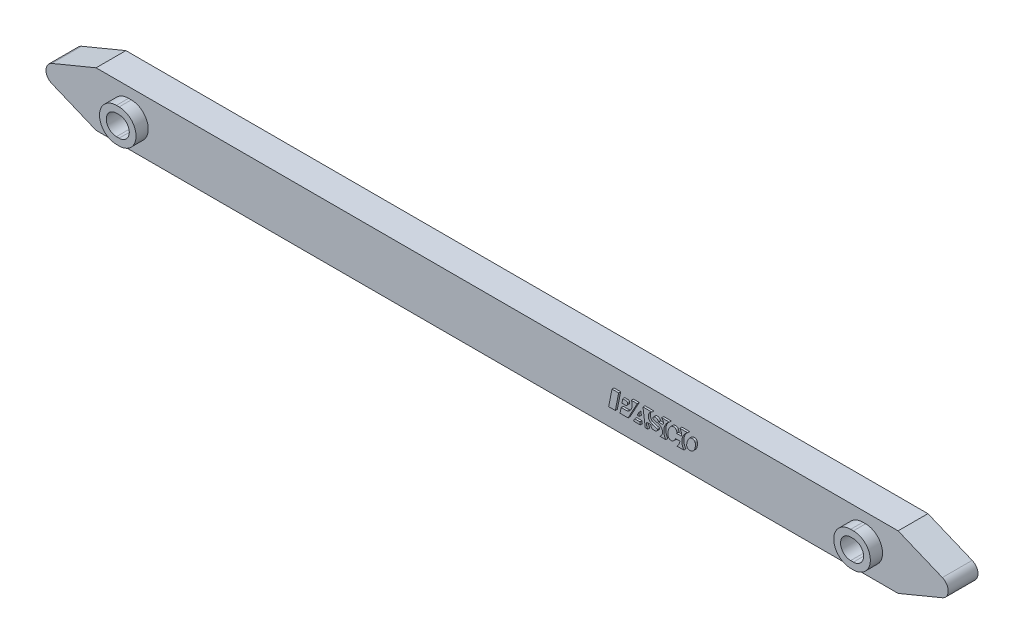
from build123d import *

# Parameters (mm, degrees)
EXTRUDE1_DEPTH      = 2.794
CUT_EXTRUDE1_DEPTH  = 6.588
SHELL2_T            = 1.016
BOSS_EXTRUDE1_DEPTH = 5.08
BOSS_EXTRUDE2_DEPTH = 0.381


with BuildPart() as part:
    # Sketch1 → Extrude1 (new body, symmetric)
    with BuildSketch(Plane.XY):
        with BuildLine():
            Line((-83.497972353, 1.642657809), (-75.199494217, 5.08))
            Line((-75.199494217, 5.08), (75.199494217, 5.08))
            Line((75.199494217, 5.08), (83.497972353, 1.642657809))
            ThreePointArc((83.497972353, 1.642657809), (84.595561211, 0), (83.497972353, -1.642657809))
            Line((83.497972353, -1.642657809), (75.199494217, -5.08))
            Line((75.199494217, -5.08), (-75.199494217, -5.08))
            Line((-75.199494217, -5.08), (-83.497972353, -1.642657809))
            ThreePointArc((-83.497972353, -1.642657809), (-84.595561211, 0), (-83.497972353, 1.642657809))
        make_face()
    extrude(amount=EXTRUDE1_DEPTH, both=True)

    # Sketch7 → Cut-Extrude1 (cut, through all)
    with BuildSketch(Plane.XY.offset(-2.794)):
        with BuildLine():
            Line((-69.101561211, -1.905), (-68.593561211, -1.905))
            ThreePointArc((-68.593561211, -1.905), (-66.688561211, 0), (-68.593561211, 1.905))
            Line((-68.593561211, 1.905), (-69.101561211, 1.905))
            ThreePointArc((-69.101561211, 1.905), (-71.006561211, 0), (-69.101561211, -1.905))
        make_face()
        with BuildLine():
            Line((69.101561211, -1.905), (68.593561211, -1.905))
            ThreePointArc((68.593561211, -1.905), (66.688561211, 0), (68.593561211, 1.905))
            Line((68.593561211, 1.905), (69.101561211, 1.905))
            ThreePointArc((69.101561211, 1.905), (71.006561211, 0), (69.101561211, -1.905))
        make_face()
    extrude(amount=CUT_EXTRUDE1_DEPTH, mode=Mode.SUBTRACT)

    # Shell2 (no face opened: a closed hollow body)
    add(offset(amount=-SHELL2_T, mode=Mode.PRIVATE), mode=Mode.SUBTRACT)

    # Sketch16 → Boss-Extrude1 (add)
    with BuildSketch(Plane.XY):
        with BuildLine():
            Line((-68.593561211, 3.175), (-69.101561211, 3.175))
            ThreePointArc((-69.101561211, 3.175), (-72.276561211, 0), (-69.101561211, -3.175))
            Line((-69.101561211, -3.175), (-68.593561211, -3.175))
            ThreePointArc((-68.593561211, -3.175), (-65.418561211, 0), (-68.593561211, 3.175))
        make_face()
        with BuildLine():
            Line((-68.593561211, 1.905), (-69.101561211, 1.905))
            ThreePointArc((-69.101561211, 1.905), (-71.006561211, 0), (-69.101561211, -1.905))
            Line((-69.101561211, -1.905), (-68.593561211, -1.905))
            ThreePointArc((-68.593561211, -1.905), (-66.688561211, 0), (-68.593561211, 1.905))
        make_face(mode=Mode.SUBTRACT)
        with BuildLine():
            Line((69.101561211, -3.175), (68.593561211, -3.175))
            ThreePointArc((68.593561211, -3.175), (65.418561211, 0), (68.593561211, 3.175))
            Line((68.593561211, 3.175), (69.101561211, 3.175))
            ThreePointArc((69.101561211, 3.175), (72.276561211, 0), (69.101561211, -3.175))
        make_face()
        with BuildLine():
            Line((69.101561211, -1.905), (68.593561211, -1.905))
            ThreePointArc((68.593561211, -1.905), (66.688561211, 0), (68.593561211, 1.905))
            Line((68.593561211, 1.905), (69.101561211, 1.905))
            ThreePointArc((69.101561211, 1.905), (71.006561211, 0), (69.101561211, -1.905))
        make_face(mode=Mode.SUBTRACT)
    extrude(amount=BOSS_EXTRUDE1_DEPTH)

    # Sketch15 → Boss-Extrude2 (add)
    with BuildSketch(Plane(origin=(52.759975214, 8.567310029, 2.794), x_dir=(-1, 0, 0), z_dir=(0, 0, 1))):
        Polygon((30.833634894, 6.909260745), (29.58586719, 6.909260745), (30.209751042, 10.080670326), (31.457518746, 10.080670326), align=None)
        with BuildLine():
            Line((26.098109724, 6.909260745), (27.818196276, 10.080670326))
            Line((27.818196276, 10.080670326), (29.325915585, 10.080670326))
            Line((29.325915585, 10.080670326), (29.121363503, 9.040863906))
            Line((29.121363503, 9.040863906), (28.076751324, 9.040863906))
            ThreePointArc((28.076751324, 9.040863906), (27.966243867, 9.027758301), (27.861867206, 8.989168567))
            ThreePointArc((27.861867206, 8.989168567), (27.110933968, 8.112530186), (27.194312424, 6.961251066))
            Line((27.194312424, 6.961251066), (27.220239704, 6.909260745))
            Line((27.220239704, 6.909260745), (26.098109724, 6.909260745))
        make_face()
        with BuildLine():
            Line((24.594796374, 10.080670326), (25.024818012, 6.909260745))
            Line((25.024818012, 6.909260745), (23.345351563, 6.909260745))
            Line((23.345351563, 6.909260745), (23.451009312, 6.961251066))
            ThreePointArc((23.451009312, 6.961251066), (24.013843502, 7.721578938), (23.720459983, 8.620915865))
            ThreePointArc((23.720459983, 8.620915865), (23.664057171, 8.668518488), (23.600928958, 8.706756109))
            ThreePointArc((23.600928958, 8.706756109), (23.03751713, 8.93797936), (22.445309842, 9.080062458))
            ThreePointArc((22.445309842, 9.080062458), (22.355999269, 9.127094259), (22.313587173, 9.218688925))
            ThreePointArc((22.313587173, 9.218688925), (22.320050836, 9.315750612), (22.359212571, 9.404796153))
            ThreePointArc((22.359212571, 9.404796153), (22.441078376, 9.50688825), (22.550436966, 9.578759697))
            ThreePointArc((22.550436966, 9.578759697), (22.912840286, 9.660745811), (23.278270345, 9.593524078))
            ThreePointArc((23.278270345, 9.593524078), (23.448349032, 9.45576593), (23.512332705, 9.246457171))
            Line((23.512332705, 9.246457171), (23.512332705, 9.040863906))
            Line((23.512332705, 9.040863906), (24.334844769, 9.040863906))
            ThreePointArc((24.334844769, 9.040863906), (24.341195101, 9.582833311), (24.126883485, 10.080670326))
            Line((24.126883485, 10.080670326), (24.594796374, 10.080670326))
        make_face()
        with BuildLine():
            Line((28.312104326, 8.261009091), (28.967949441, 8.261009091))
            Line((28.967949441, 8.261009091), (28.814535379, 7.481154276))
            Line((28.814535379, 7.481154276), (28.209554826, 7.481154276))
            ThreePointArc((28.209554826, 7.481154276), (28.006347959, 7.565325317), (27.922176918, 7.768532184))
            Line((27.922176918, 7.768532184), (27.922176918, 7.871081684))
            ThreePointArc((27.922176918, 7.871081684), (28.036384012, 8.146801998), (28.312104326, 8.261009091))
        make_face()
        Polygon((25.790573757, 8.16352724), (25.706860528, 8.780912301), (26.125426672, 8.780912301), align=None)
        Polygon((25.530622152, 10.080670326), (26.830380177, 10.080670326), (26.576596915, 9.612757437), (25.594067968, 9.612757437), align=None)
        with BuildLine():
            Line((21.446019985, 6.986900983), (21.527856602, 6.905064366))
            Line((21.527856602, 6.905064366), (20.072127614, 6.905064366))
            ThreePointArc((20.072127614, 6.905064366), (21.073440916, 8.351729074), (20.74751262, 10.080670326))
            Line((20.74751262, 10.080670326), (21.839309361, 10.080670326))
            ThreePointArc((21.839309361, 10.080670326), (21.359771514, 9.203641008), (21.828371735, 8.320719265))
            ThreePointArc((21.828371735, 8.320719265), (21.970498458, 8.242561464), (22.123897961, 8.189861942))
            Line((22.123897961, 8.189861942), (22.959965448, 7.98084507))
            ThreePointArc((22.959965448, 7.98084507), (23.09929103, 7.88260745), (23.136218517, 7.716178461))
            ThreePointArc((23.136218517, 7.716178461), (23.063353728, 7.552354455), (22.917107557, 7.44862577))
            ThreePointArc((22.917107557, 7.44862577), (22.408346515, 7.486786133), (22.100511774, 7.893642107))
            Line((22.100511774, 7.893642107), (21.268666638, 7.893642107))
            ThreePointArc((21.268666638, 7.893642107), (21.219023851, 7.413217054), (21.446019985, 6.986900983))
        make_face()
        with BuildLine():
            Line((18.096006249, 6.909260745), (16.640277261, 6.909260745))
            ThreePointArc((16.640277261, 6.909260745), (17.684029363, 8.338941307), (17.368141755, 10.080670326))
            Line((17.368141755, 10.080670326), (18.66789978, 10.080670326))
            ThreePointArc((18.66789978, 10.080670326), (18.288993246, 9.583465168), (18.096006249, 8.988873585))
            Line((18.096006249, 8.988873585), (18.927851385, 8.988873585))
            ThreePointArc((18.927851385, 8.988873585), (19.124730401, 9.376543005), (19.462251482, 9.650638693))
            ThreePointArc((19.462251482, 9.650638693), (20.018996521, 9.643076799), (20.333746509, 9.183778785))
            ThreePointArc((20.333746509, 9.183778785), (20.297634521, 8.424922889), (20.010357156, 7.72161779))
            ThreePointArc((20.010357156, 7.72161779), (19.734264238, 7.404457918), (19.340648899, 7.256523307))
            ThreePointArc((19.340648899, 7.256523307), (18.807293319, 7.48101259), (18.719890101, 8.053047807))
            Line((18.719890101, 8.053047807), (17.784064323, 8.053047807))
            ThreePointArc((17.784064323, 8.053047807), (17.822649734, 7.449140035), (18.096006249, 6.909260745))
        make_face()
        with BuildLine():
            Line((15.807268249, 7.427425154), (15.715290544, 7.427425154))
            ThreePointArc((15.715290544, 7.427425154), (15.394442736, 7.543776842), (15.22275385, 7.838741175))
            ThreePointArc((15.22275385, 7.838741175), (15.210743896, 8.452467568), (15.392018164, 9.038934928))
            ThreePointArc((15.392018164, 9.038934928), (15.644599766, 9.361161911), (16.00483435, 9.555735132))
            ThreePointArc((16.00483435, 9.555735132), (16.126082831, 9.577672377), (16.249203287, 9.582549899))
            ThreePointArc((16.249203287, 9.582549899), (16.671437038, 9.390945472), (16.831737964, 8.95586248))
            ThreePointArc((16.831737964, 8.95586248), (16.709931987, 8.31539524), (16.410014233, 7.736530556))
            ThreePointArc((16.410014233, 7.736530556), (16.145960171, 7.509207095), (15.807268249, 7.427425154))
        make_face()
    extrude(amount=BOSS_EXTRUDE2_DEPTH)


solid = part.part
